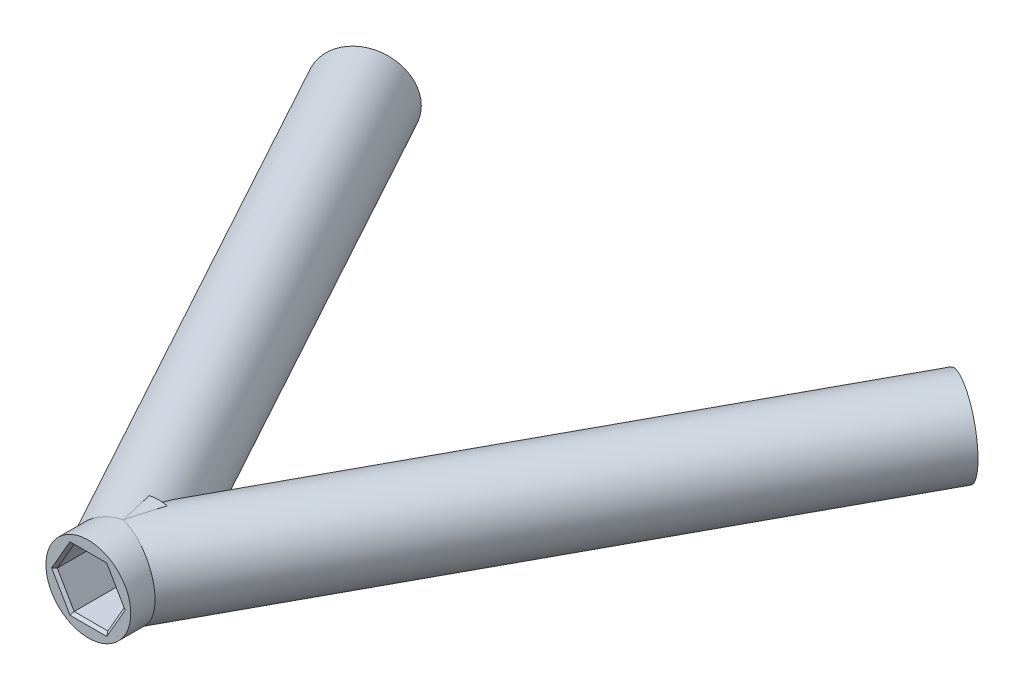
from build123d import *

# Parameters (mm, degrees)
SKETCH1_W           = 4
SKETCH1_H           = 6.6
BOSS_EXTRUDE1_REACH = 63.704
SKETCH21_R          = 4
BOSS_EXTRUDE2_REACH = 77.825
SKETCH22_R          = 4
CUT_EXTRUDE3_DEPTH  = 6.6
CUT_EXTRUDE4_DEPTH  = 6.6
CUT_EXTRUDE5_DEPTH  = 6.6
CHAMFER2_SIZE       = 0.25


with BuildPart() as part:
    # Sketch1 → Revolve-Thin1 (revolve)
    with BuildSketch(Plane(origin=(0, 0, 0), x_dir=(1, 0, 0), z_dir=(0, 1, 0))):
        with Locations((-2, 20.8)):
            Rectangle(SKETCH1_W, SKETCH1_H)
    revolve(axis=Axis((0, 0, -17.5), (0, 0, -1)))

    # Sketch21 → Boss-Extrude1 (add, up to next)
    with BuildSketch(Plane(origin=(-36.020185124, 0, -65.949410445), x_dir=(0.877628145, 0, -0.47934209), z_dir=(0.47934209, 0, 0.877628145)), mode=Mode.PRIVATE) as boss_extrude1_sk1:
        with Locations((9.970315475, 0)):
            Circle(SKETCH21_R)
    boss_extrude1_tool1 = extrude(boss_extrude1_sk1.sketch, amount=BOSS_EXTRUDE1_REACH, mode=Mode.PRIVATE) - part.part
    add(boss_extrude1_tool1.solids().sort_by_distance((-27.269956, 0, -70.728602))[0])

    # Sketch22 → Boss-Extrude2 (add, up to next)
    with BuildSketch(Plane(origin=(36.540728539, 0, -67.204649662), x_dir=(0.878534203, 0, 0.477679446), z_dir=(-0.477679446, 0, 0.878534203)), mode=Mode.PRIVATE) as boss_extrude2_sk1:
        with Locations((-9.935732483, 0)):
            Circle(SKETCH22_R)
    boss_extrude2_tool1 = extrude(boss_extrude2_sk1.sketch, amount=BOSS_EXTRUDE2_REACH, mode=Mode.PRIVATE) - part.part
    add(boss_extrude2_tool1.solids().sort_by_distance((27.811848, 0, -71.950745))[0])

    # Sketch29 → Cut-Extrude3 (cut)
    with BuildSketch(Plane(origin=(-36.020185124, 0, -65.949410445), x_dir=(-0.877628145, 0, 0.47934209), z_dir=(-0.47934209, 0, -0.877628145))):
        Polygon((-7.031266698, 1.20221696), (-9.541941515, 3.146399384), (-12.480990292, 1.944182424), (-12.909364252, -1.20221696), (-10.398689436, -3.146399384), (-7.459640658, -1.944182424), align=None)
    extrude(amount=-CUT_EXTRUDE3_DEPTH, mode=Mode.SUBTRACT)

    # Sketch30 → Cut-Extrude4 (cut)
    with BuildSketch(Plane(origin=(36.540728539, 0, -67.204649662), x_dir=(-0.878534203, 0, -0.477679446), z_dir=(0.477679446, 0, -0.878534203))):
        Polygon((12.87478126, 1.20221696), (10.364106444, 3.146399384), (7.425057666, 1.944182424), (6.996683706, -1.20221696), (9.507358523, -3.146399384), (12.4464073, -1.944182424), align=None)
    extrude(amount=-CUT_EXTRUDE4_DEPTH, mode=Mode.SUBTRACT)

    # Sketch18 → Cut-Extrude5 (cut)
    with BuildSketch(Plane.XY.offset(-17.5)):
        Polygon((1.58771324, 2.75), (-1.58771324, 2.75), (-3.175426481, 0), (-1.58771324, -2.75), (1.58771324, -2.75), (3.175426481, 0), align=None)
    extrude(amount=-CUT_EXTRUDE5_DEPTH, mode=Mode.SUBTRACT)

    # Chamfer2
    chamfer2_edges = [part.edges().sort_by_distance(p)[0] for p in [
        (-29.661371054, -0.370982732, -69.422461356),
        (-28.747628135, 2.174308172, -69.921528578),
        (-26.356212732, 2.545290904, -71.227669527),
        (-24.878540246, 0.370982732, -72.034743254),
        (-25.792283165, -2.174308172, -71.535676032),
        (-28.183698569, -2.545290904, -70.229535082),
        (25.417963429, -0.370982732, -73.252355328),
        (26.332649691, 2.174308172, -72.755019168),
        (28.726533979, 2.545290904, -71.453408693),
        (30.205732005, 0.370982732, -70.649134379),
        (29.291045743, -2.174308172, -71.146470539),
        (26.897161455, -2.545290904, -72.448081013),
        (2.38156986, 1.375, -17.5),
        (0, 2.75, -17.5),
        (-2.38156986, 1.375, -17.5),
        (-2.38156986, -1.375, -17.5),
        (0, -2.75, -17.5),
        (2.38156986, -1.375, -17.5),
    ]]
    chamfer(chamfer2_edges, length=CHAMFER2_SIZE)


solid = part.part
